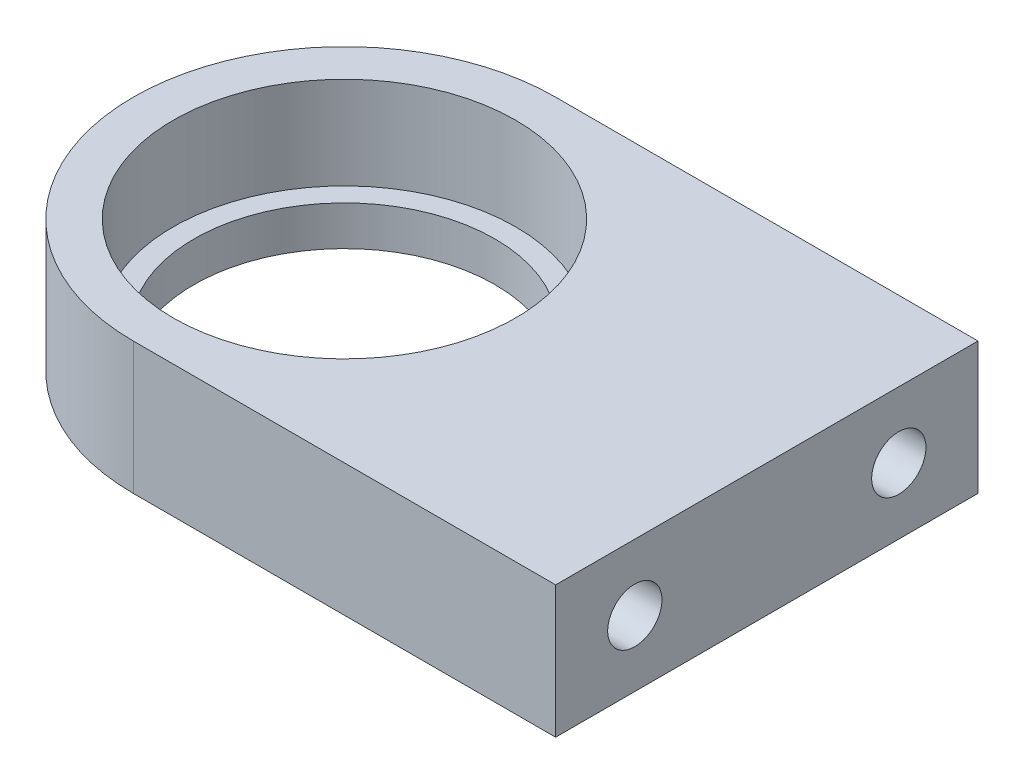
from build123d import *

# Parameters (mm, degrees)
SKETCH1_W           = 76.2
SKETCH1_H           = 50.8
BOSS_EXTRUDE1_DEPTH = 7.9375
SKETCH2_R           = 20.5994
CUT_EXTRUDE1_DEPTH  = 11.1125
SKETCH3_R           = 18.0975
CUT_EXTRUDE2_DEPTH  = 12.7
SKETCH7_R           = 3.2639
CUT_EXTRUDE6_DEPTH  = 19.05
CUT_EXTRUDE7_DEPTH  = 16.875


with BuildPart() as part:
    # Sketch1 → Boss-Extrude1 (new body, symmetric)
    with BuildSketch(Plane(origin=(0, 0, 0), x_dir=(1, 0, 0), z_dir=(0, 1, 0))):
        with Locations((12.7, 0)):
            Rectangle(SKETCH1_W, SKETCH1_H)
    extrude(amount=BOSS_EXTRUDE1_DEPTH, both=True)

    # Sketch2 → Cut-Extrude1 (cut)
    with BuildSketch(Plane(origin=(0, 7.9375, 0), x_dir=(1, 0, 0), z_dir=(0, 1, 0))):
        Circle(SKETCH2_R)
    extrude(amount=-CUT_EXTRUDE1_DEPTH, mode=Mode.SUBTRACT)

    # Sketch3 → Cut-Extrude2 (cut)
    with BuildSketch(Plane(origin=(0, -3.175, 0), x_dir=(1, 0, 0), z_dir=(0, 1, 0))):
        Circle(SKETCH3_R)
    extrude(amount=-CUT_EXTRUDE2_DEPTH, mode=Mode.SUBTRACT)

    # Sketch7 → Cut-Extrude6 (cut)
    with BuildSketch(Plane(origin=(50.8, 0, 0), x_dir=(0, 0, -1), z_dir=(1, 0, 0))):
        with Locations((-15.875, 0)):
            Circle(SKETCH7_R)
        with Locations((15.875, 0)):
            Circle(SKETCH7_R)
    extrude(amount=-CUT_EXTRUDE6_DEPTH, mode=Mode.SUBTRACT)

    # Sketch8 → Cut-Extrude7 (cut, through all)
    with BuildSketch(Plane(origin=(0, 7.9375, 0), x_dir=(1, 0, 0), z_dir=(0, 1, 0))):
        with BuildLine():
            Line((0, -25.4), (0, -38.1))
            Line((0, -38.1), (-50.8, -38.1))
            Line((-50.8, -38.1), (-50.8, 38.1))
            Line((-50.8, 38.1), (0, 38.1))
            Line((0, 38.1), (0, 25.4))
            ThreePointArc((0, 25.4), (-25.4, 0), (0, -25.4))
        make_face()
    extrude(amount=-CUT_EXTRUDE7_DEPTH, mode=Mode.SUBTRACT)


solid = part.part
